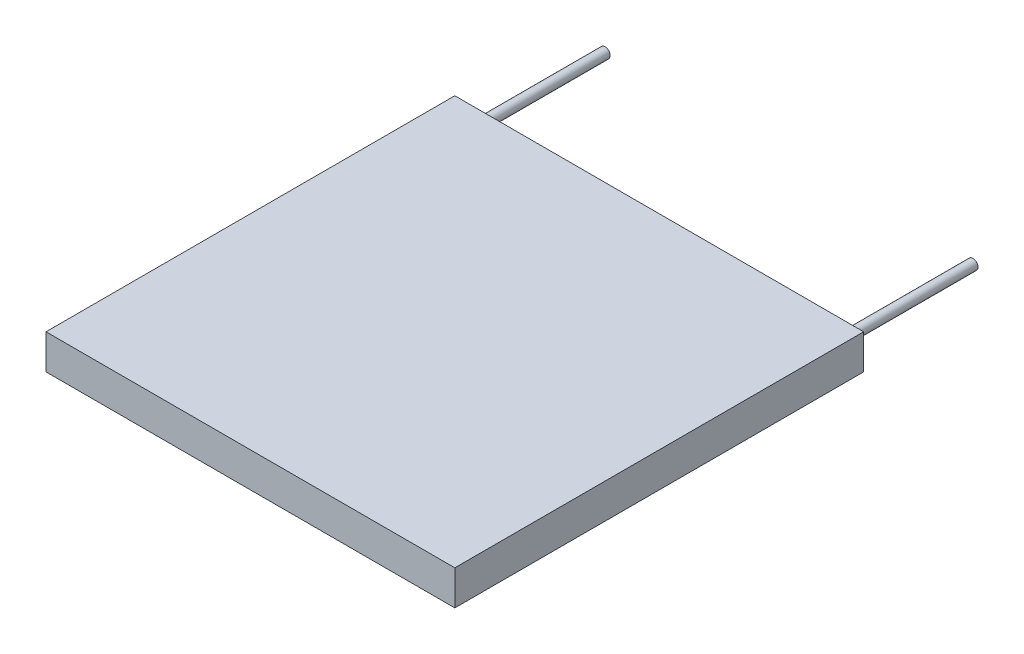
from build123d import *

# Parameters (mm, degrees)
SKETCH1_W           = 40
SKETCH1_H           = 40
BOSS_EXTRUDE1_DEPTH = 3.4
SKETCH2_R           = 0.5
BOSS_EXTRUDE2_DEPTH = 12.7
SKETCH3_R           = 0.4953
BOSS_EXTRUDE3_DEPTH = 12.7


with BuildPart() as part:
    # Sketch1 → Boss-Extrude1 (new body)
    with BuildSketch(Plane(origin=(0, 0, 0), x_dir=(1, 0, 0), z_dir=(0, 1, 0))):
        with Locations((-30.671871438, 7.059468761)):
            Rectangle(SKETCH1_W, SKETCH1_H)
    extrude(amount=BOSS_EXTRUDE1_DEPTH)

    # Sketch2 → Boss-Extrude2 (add)
    with BuildSketch(Plane(origin=(0, 0, -27.059468761), x_dir=(-1, 0, 0), z_dir=(0, 0, -1))):
        with Locations((48.671871438, 1.7)):
            Circle(SKETCH2_R)
    extrude(amount=BOSS_EXTRUDE2_DEPTH)

    # Sketch3 → Boss-Extrude3 (add)
    with BuildSketch(Plane(origin=(0, 0, -27.059468761), x_dir=(-1, 0, 0), z_dir=(0, 0, -1))):
        with Locations((12.678471438, 1.772009117)):
            Circle(SKETCH3_R)
    extrude(amount=BOSS_EXTRUDE3_DEPTH)


solid = part.part
